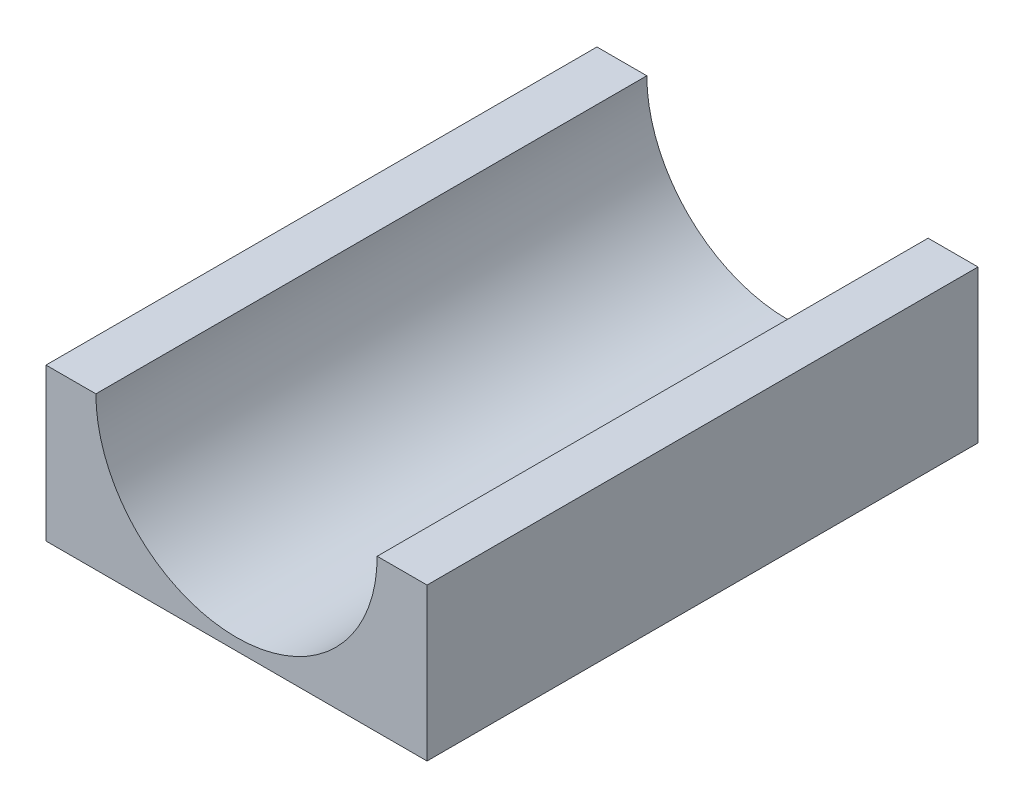
from build123d import *

# Parameters (mm, degrees)
SKETCH1_W           = 50.8
SKETCH1_H           = 73.449999912
BOSS_EXTRUDE1_DEPTH = 20.32
CUT_EXTRUDE1_REACH  = 75.45
SKETCH2_R           = 18.749999965


with BuildPart() as part:
    # Sketch1 → Boss-Extrude1 (new body)
    with BuildSketch(Plane(origin=(0, 0, 0), x_dir=(1, 0, 0), z_dir=(0, 1, 0))):
        Rectangle(SKETCH1_W, SKETCH1_H)
    extrude(amount=BOSS_EXTRUDE1_DEPTH)

    # Sketch2 → Cut-Extrude1 (cut, up to next)
    with BuildSketch(Plane.XY.offset(36.724999956), mode=Mode.PRIVATE) as cut_extrude1_sk1:
        with Locations((0, 20.32)):
            Circle(SKETCH2_R)
    cut_extrude1_tool1 = extrude(cut_extrude1_sk1.sketch, amount=-CUT_EXTRUDE1_REACH, mode=Mode.PRIVATE) & part.part
    add(cut_extrude1_tool1.solids().sort_by_distance((0, 20.32, 36.725))[0], mode=Mode.SUBTRACT)


solid = part.part
